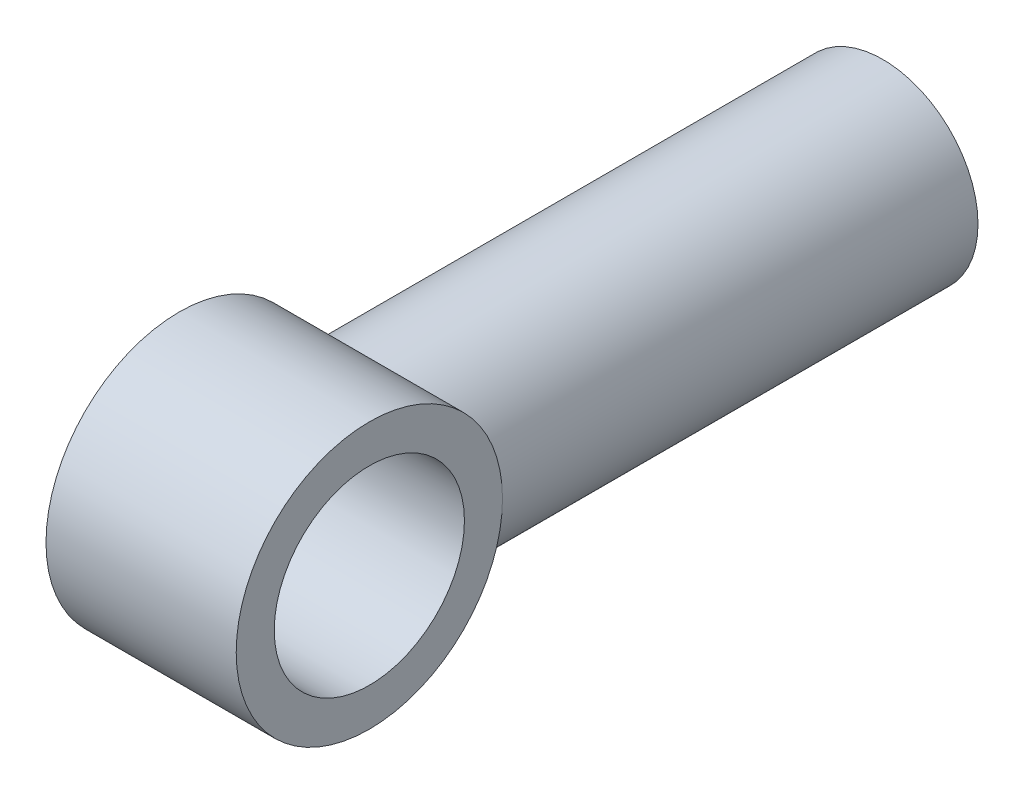
from build123d import *

# Parameters (mm, degrees)
SKETCH2_R           = 3.175
BOSS_EXTRUDE1_DEPTH = 20.32
SKETCH3_R           = 4.445
BOSS_EXTRUDE2_DEPTH = 3.175
SKETCH4_R           = 3.175
CUT_EXTRUDE1_DEPTH  = 6.35


with BuildPart() as part:
    # Sketch2 → Boss-Extrude1 (new body)
    with BuildSketch(Plane.XY):
        Circle(SKETCH2_R)
    extrude(amount=-BOSS_EXTRUDE1_DEPTH)

    # Sketch3 → Boss-Extrude2 (add, symmetric)
    with BuildSketch(Plane(origin=(0, 0, 0), x_dir=(0, 0, -1), z_dir=(1, 0, 0))):
        Circle(SKETCH3_R)
    extrude(amount=BOSS_EXTRUDE2_DEPTH, both=True)

    # Sketch4 → Cut-Extrude1 (cut)
    with BuildSketch(Plane(origin=(3.175, 0, 0), x_dir=(0, 0, -1), z_dir=(1, 0, 0))):
        Circle(SKETCH4_R)
    extrude(amount=-CUT_EXTRUDE1_DEPTH, mode=Mode.SUBTRACT)


solid = part.part
